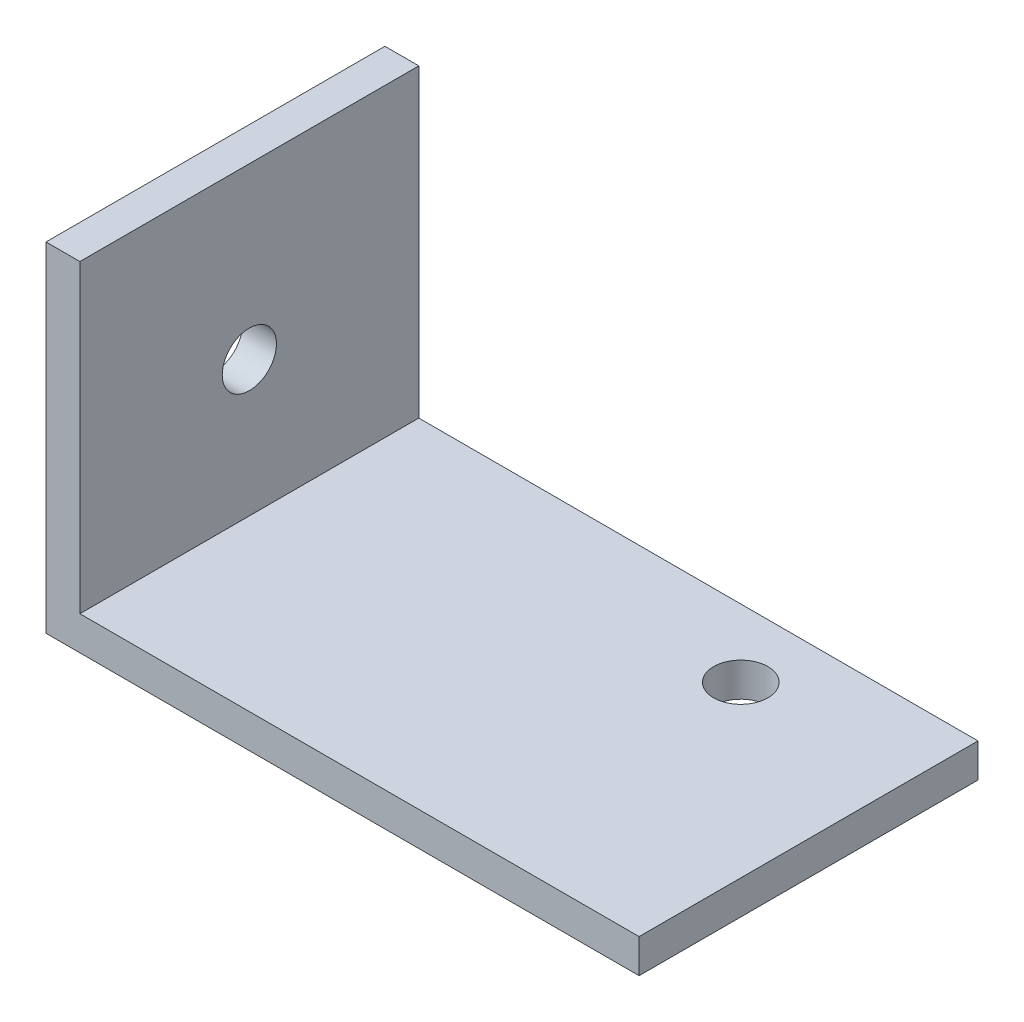
from build123d import *

# Parameters (mm, degrees)
EXTRUDE_1_DEPTH     = 20
SKETCH_2_R          = 1.6
CUT_EXTRUDE_1_DEPTH = 21
SKETCH_3_R          = 1.6
CUT_EXTRUDE_2_DEPTH = 36


with BuildPart() as part:
    # Эскиз1 → Бобышка-Вытянуть1 (new body)
    with BuildSketch(Plane.XY):
        Polygon((0, 0), (35, 0), (35, 2), (2, 2), (2, 20), (0, 20), align=None)
    extrude(amount=EXTRUDE_1_DEPTH)

    # Эскиз2 → Вырез-Вытянуть1 (cut, through all)
    with BuildSketch(Plane.XZ):
        with Locations((25, 4)):
            Circle(SKETCH_2_R)
    extrude(amount=-CUT_EXTRUDE_1_DEPTH, mode=Mode.SUBTRACT)

    # Эскиз3 → Вырез-Вытянуть2 (cut, through all)
    with BuildSketch(Plane.ZY):
        with Locations((10, 10)):
            Circle(SKETCH_3_R)
    extrude(amount=-CUT_EXTRUDE_2_DEPTH, mode=Mode.SUBTRACT)


solid = part.part
